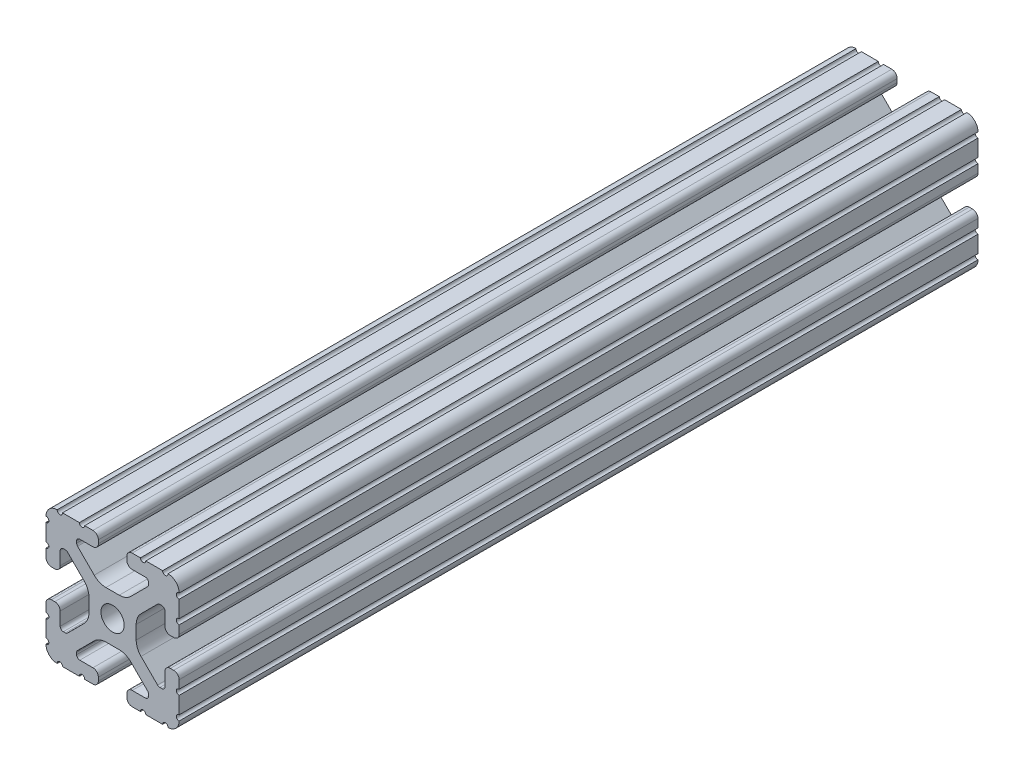
from build123d import *

# Parameters (mm, degrees)
SKETCH3_R                = 3.3274
BOSS_EXTRUDE1_DEPTH      = 457.2
BOSS_EXTRUDE1_DEPTH_BACK = 457.2
CUT_EXTRUDE1_DEPTH       = 22.86


with BuildPart() as part:
    # Sketch3 → Boss-Extrude1 (new body, two sides)
    with BuildSketch(Plane.XY) as boss_extrude1_sk:
        with BuildLine():
            Line((-4.064, 16.539617549), (-4.064, 17.496382451))
            ThreePointArc((-4.064, 17.496382451), (-4.519044045, 18.594955955), (-5.617617549, 19.05))
            Line((-5.617617549, 19.05), (-7.974178704, 19.05))
            ThreePointArc((-7.974178704, 19.05), (-8.736178704, 18.288), (-9.498178704, 19.05))
            Line((-9.498178704, 19.05), (-14.327719207, 19.05))
            ThreePointArc((-14.327719207, 19.05), (-15.087603123, 18.231251131), (-15.847487039, 19.05))
            ThreePointArc((-15.847487039, 19.05), (-18.120176289, 18.120192083), (-19.05, 15.847509295))
            ThreePointArc((-19.05, 15.847509295), (-18.231250992, 15.08762539), (-19.05, 14.327741484))
            Line((-19.05, 14.327741484), (-19.05, 9.496091471))
            ThreePointArc((-19.05, 9.496091471), (-18.231250992, 8.736207565), (-19.05, 7.97632366))
            Line((-19.05, 7.97632366), (-19.05, 5.617617549))
            ThreePointArc((-19.05, 5.617617549), (-18.594955955, 4.519044045), (-17.496382451, 4.064))
            Line((-17.496382451, 4.064), (-16.539617549, 4.064))
            ThreePointArc((-16.539617549, 4.064), (-15.441044045, 4.519044045), (-14.986, 5.617617549))
            Line((-14.986, 5.617617549), (-14.986, 9.385342516))
            ThreePointArc((-14.986, 9.385342516), (-14.721898185, 10.022940701), (-14.0843, 10.287042516))
            Line((-14.0843, 10.287042516), (-13.516042086, 10.287042516))
            ThreePointArc((-13.516042086, 10.287042516), (-13.170975923, 10.218404478), (-12.878443117, 10.022939917))
            Line((-12.878443117, 10.022939917), (-8.14758008, 5.292065243))
            ThreePointArc((-8.14758008, 5.292065243), (-7.117955879, 3.751120653), (-6.7564, 1.933453584))
            Line((-6.7564, 1.933453584), (-6.7564, -1.933453584))
            ThreePointArc((-6.7564, -1.933453584), (-7.117955879, -3.751120653), (-8.14758008, -5.292065243))
            Line((-8.14758008, -5.292065243), (-12.878443117, -10.022939917))
            ThreePointArc((-12.878443117, -10.022939917), (-13.170975923, -10.218404478), (-13.516042086, -10.287042516))
            Line((-13.516042086, -10.287042516), (-14.0843, -10.287042516))
            ThreePointArc((-14.0843, -10.287042516), (-14.721898185, -10.022940701), (-14.986, -9.385342516))
            Line((-14.986, -9.385342516), (-14.986, -5.617617549))
            ThreePointArc((-14.986, -5.617617549), (-15.441044045, -4.519044045), (-16.539617549, -4.064))
            Line((-16.539617549, -4.064), (-17.496382451, -4.064))
            ThreePointArc((-17.496382451, -4.064), (-18.594955955, -4.519044045), (-19.05, -5.617617549))
            Line((-19.05, -5.617617549), (-19.05, -7.976318491))
            ThreePointArc((-19.05, -7.976318491), (-18.231250992, -8.736202396), (-19.05, -9.496086302))
            Line((-19.05, -9.496086302), (-19.05, -14.32774291))
            ThreePointArc((-19.05, -14.32774291), (-18.231250992, -15.087626816), (-19.05, -15.847510721))
            ThreePointArc((-19.05, -15.847510721), (-18.120175716, -18.120192644), (-15.847486868, -19.05))
            ThreePointArc((-15.847486868, -19.05), (-15.087602952, -18.231251131), (-14.327719036, -19.05))
            Line((-14.327719036, -19.05), (-9.496062448, -19.05))
            ThreePointArc((-9.496062448, -19.05), (-8.736178532, -18.231251131), (-7.976294616, -19.05))
            Line((-7.976294616, -19.05), (-5.617617549, -19.05))
            ThreePointArc((-5.617617549, -19.05), (-4.519044045, -18.594955955), (-4.064, -17.496382451))
            Line((-4.064, -17.496382451), (-4.064, -16.539617549))
            ThreePointArc((-4.064, -16.539617549), (-4.519044045, -15.441044045), (-5.617617549, -14.986))
            Line((-5.617617549, -14.986), (-9.3853, -14.986))
            ThreePointArc((-9.3853, -14.986), (-10.022898185, -14.721898185), (-10.287, -14.0843))
            Line((-10.287, -14.0843), (-10.287, -13.552357131))
            ThreePointArc((-10.287, -13.552357131), (-10.218362387, -13.207291992), (-10.022898969, -12.91475973))
            Line((-10.022898969, -12.91475973), (-5.252158105, -8.144007132))
            ThreePointArc((-5.252158105, -8.144007132), (-3.715177372, -7.117027388), (-1.902183975, -6.7564))
            Line((-1.902183975, -6.7564), (1.902183975, -6.7564))
            ThreePointArc((1.902183975, -6.7564), (3.715177372, -7.117027388), (5.252158105, -8.144007132))
            Line((5.252158105, -8.144007132), (10.022898969, -12.91475973))
            ThreePointArc((10.022898969, -12.91475973), (10.218362387, -13.207291992), (10.287, -13.552357131))
            Line((10.287, -13.552357131), (10.287, -14.0843))
            ThreePointArc((10.287, -14.0843), (10.022898185, -14.721898185), (9.3853, -14.986))
            Line((9.3853, -14.986), (5.617617549, -14.986))
            ThreePointArc((5.617617549, -14.986), (4.519044045, -15.441044045), (4.064, -16.539617549))
            Line((4.064, -16.539617549), (4.064, -17.496382451))
            ThreePointArc((4.064, -17.496382451), (4.519044045, -18.594955955), (5.617617549, -19.05))
            Line((5.617617549, -19.05), (7.976294616, -19.05))
            ThreePointArc((7.976294616, -19.05), (8.736178532, -18.231251131), (9.496062448, -19.05))
            Line((9.496062448, -19.05), (14.327719036, -19.05))
            ThreePointArc((14.327719036, -19.05), (15.087602952, -18.231251131), (15.847486868, -19.05))
            ThreePointArc((15.847486868, -19.05), (18.120175716, -18.120192644), (19.05, -15.847510721))
            ThreePointArc((19.05, -15.847510721), (18.231250992, -15.087626816), (19.05, -14.32774291))
            Line((19.05, -14.32774291), (19.05, -9.496086302))
            ThreePointArc((19.05, -9.496086302), (18.231250992, -8.736202396), (19.05, -7.976318491))
            Line((19.05, -7.976318491), (19.05, -5.617617549))
            ThreePointArc((19.05, -5.617617549), (18.594955955, -4.519044045), (17.496382451, -4.064))
            Line((17.496382451, -4.064), (16.539617549, -4.064))
            ThreePointArc((16.539617549, -4.064), (15.441044045, -4.519044045), (14.986, -5.617617549))
            Line((14.986, -5.617617549), (14.986, -9.385342516))
            ThreePointArc((14.986, -9.385342516), (14.721898185, -10.022940701), (14.0843, -10.287042516))
            Line((14.0843, -10.287042516), (13.516042086, -10.287042516))
            ThreePointArc((13.516042086, -10.287042516), (13.170975923, -10.218404478), (12.878443117, -10.022939917))
            Line((12.878443117, -10.022939917), (8.14758008, -5.292065243))
            ThreePointArc((8.14758008, -5.292065243), (7.117955879, -3.751120653), (6.7564, -1.933453584))
            Line((6.7564, -1.933453584), (6.7564, 1.933453584))
            ThreePointArc((6.7564, 1.933453584), (7.117955879, 3.751120653), (8.14758008, 5.292065243))
            Line((8.14758008, 5.292065243), (12.878443117, 10.022939917))
            ThreePointArc((12.878443117, 10.022939917), (13.170975923, 10.218404478), (13.516042086, 10.287042516))
            Line((13.516042086, 10.287042516), (14.0843, 10.287042516))
            ThreePointArc((14.0843, 10.287042516), (14.721898185, 10.022940701), (14.986, 9.385342516))
            Line((14.986, 9.385342516), (14.986, 5.617617549))
            ThreePointArc((14.986, 5.617617549), (15.441044045, 4.519044045), (16.539617549, 4.064))
            Line((16.539617549, 4.064), (17.496382451, 4.064))
            ThreePointArc((17.496382451, 4.064), (18.594955955, 4.519044045), (19.05, 5.617617549))
            Line((19.05, 5.617617549), (19.05, 7.97632366))
            ThreePointArc((19.05, 7.97632366), (18.231250992, 8.736207565), (19.05, 9.496091471))
            Line((19.05, 9.496091471), (19.05, 14.327741484))
            ThreePointArc((19.05, 14.327741484), (18.231250992, 15.08762539), (19.05, 15.847509295))
            ThreePointArc((19.05, 15.847509295), (18.120176289, 18.120192083), (15.847487039, 19.05))
            ThreePointArc((15.847487039, 19.05), (15.087603123, 18.231251131), (14.327719207, 19.05))
            Line((14.327719207, 19.05), (9.498178704, 19.05))
            ThreePointArc((9.498178704, 19.05), (8.736178704, 18.288), (7.974178704, 19.05))
            Line((7.974178704, 19.05), (5.617617549, 19.05))
            ThreePointArc((5.617617549, 19.05), (4.519044045, 18.594955955), (4.064, 17.496382451))
            Line((4.064, 17.496382451), (4.064, 16.539617549))
            ThreePointArc((4.064, 16.539617549), (4.519044045, 15.441044045), (5.617617549, 14.986))
            Line((5.617617549, 14.986), (9.3853, 14.986))
            ThreePointArc((9.3853, 14.986), (10.022898185, 14.721898185), (10.287, 14.0843))
            Line((10.287, 14.0843), (10.287, 13.552357131))
            ThreePointArc((10.287, 13.552357131), (10.218362387, 13.207291992), (10.022898969, 12.91475973))
            Line((10.022898969, 12.91475973), (5.252158105, 8.144007132))
            ThreePointArc((5.252158105, 8.144007132), (3.715177372, 7.117027388), (1.902183975, 6.7564))
            Line((1.902183975, 6.7564), (-1.902183975, 6.7564))
            ThreePointArc((-1.902183975, 6.7564), (-3.715177372, 7.117027388), (-5.252158105, 8.144007132))
            Line((-5.252158105, 8.144007132), (-10.022898969, 12.91475973))
            ThreePointArc((-10.022898969, 12.91475973), (-10.218362387, 13.207291992), (-10.287, 13.552357131))
            Line((-10.287, 13.552357131), (-10.287, 14.0843))
            ThreePointArc((-10.287, 14.0843), (-10.022898185, 14.721898185), (-9.3853, 14.986))
            Line((-9.3853, 14.986), (-5.617617549, 14.986))
            ThreePointArc((-5.617617549, 14.986), (-4.519044045, 15.441044045), (-4.064, 16.539617549))
        make_face()
        Circle(SKETCH3_R, mode=Mode.SUBTRACT)
    extrude(amount=BOSS_EXTRUDE1_DEPTH)
    extrude(boss_extrude1_sk.sketch, amount=-BOSS_EXTRUDE1_DEPTH_BACK)

    # Sketch4 → Cut-Extrude1 (cut, symmetric)
    with BuildSketch(Plane(origin=(0, 0, 0), x_dir=(1, 0, 0), z_dir=(0, 1, 0))):
        Polygon((-11.912948955, 228.6), (-26.025980117, 228.6), (-26.025980117, -478.373467622), (32.635256624, -478.373467622), (32.635256624, 228.6), align=None)
    extrude(amount=CUT_EXTRUDE1_DEPTH, both=True, mode=Mode.SUBTRACT)


solid = part.part
